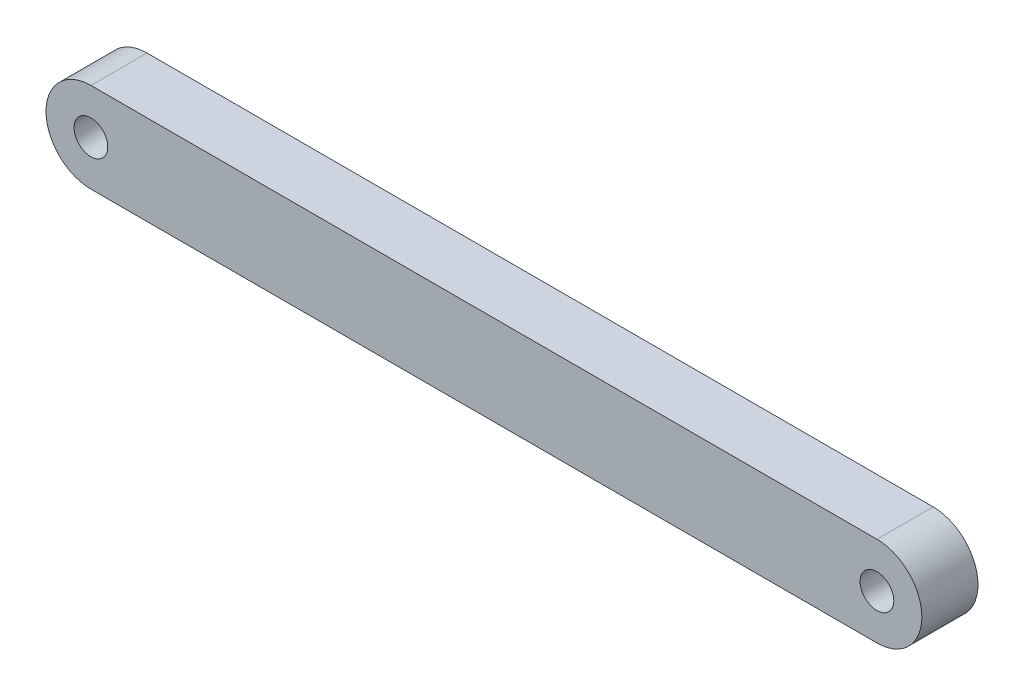
from build123d import *

# Parameters (mm, degrees)
SKETCH1_R           = 1.5
BOSS_EXTRUDE1_DEPTH = 5


with BuildPart() as part:
    # Sketch1 → Boss-Extrude1 (new body)
    with BuildSketch(Plane.XY):
        with BuildLine():
            Line((0, 4), (70, 4))
            ThreePointArc((70, 4), (74, 0), (70, -4))
            Line((70, -4), (0, -4))
            ThreePointArc((0, -4), (-4, 0), (0, 4))
        make_face()
        Circle(SKETCH1_R, mode=Mode.SUBTRACT)
        with Locations((70, 0)):
            Circle(SKETCH1_R, mode=Mode.SUBTRACT)
    extrude(amount=BOSS_EXTRUDE1_DEPTH)


solid = part.part
